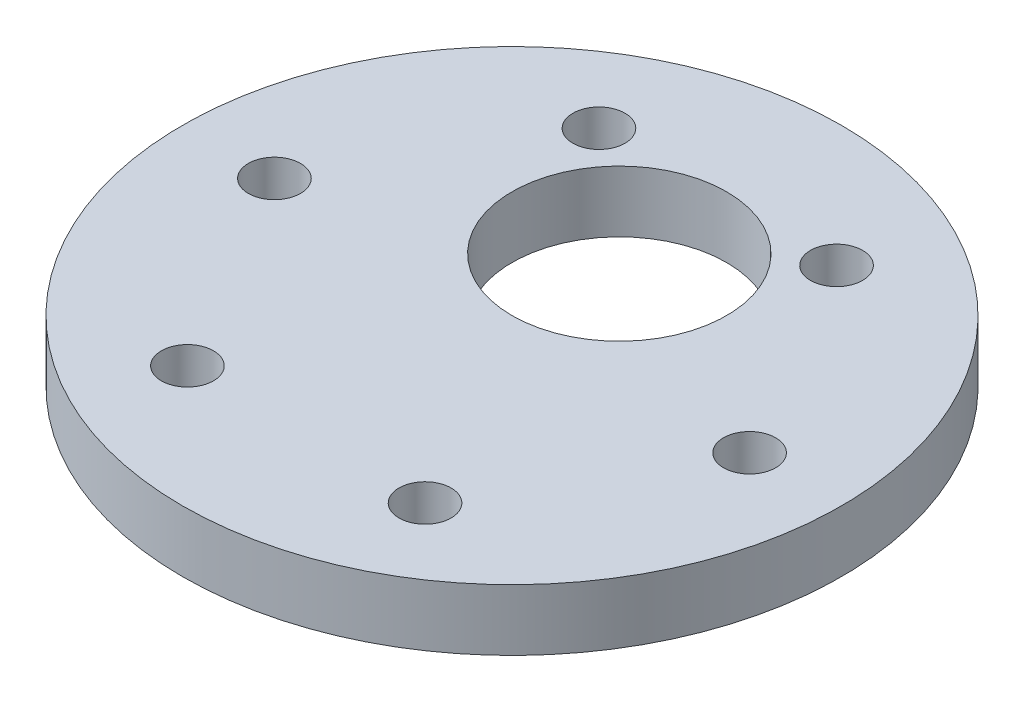
from build123d import *

# Parameters (mm, degrees)
SKETCH3_R           = 21.5
SKETCH3_R_2         = 7
BOSS_EXTRUDE1_DEPTH = 4
SKETCH3_4_R         = 1.7
CUT_EXTRUDE2_DEPTH  = 4
CIRPATTERN1_COUNT   = 6


with BuildPart() as part:
    # Sketch3 → Boss-Extrude1 (new body)
    with BuildSketch(Plane(origin=(0, 0, 0), x_dir=(1, 0, 0), z_dir=(0, 1, 0))):
        Circle(SKETCH3_R)
        with Locations((0, 7)):
            Circle(SKETCH3_R_2, mode=Mode.SUBTRACT)
    extrude(amount=BOSS_EXTRUDE1_DEPTH)

    # Sketch3_4 → Cut-Extrude2 (cut)
    with BuildSketch(Plane(origin=(0, 0, 0), x_dir=(1, 0, 0), z_dir=(0, 1, 0))):
        with Locations((-15.5, 0)):
            Circle(SKETCH3_4_R)
    cut_extrude2 = extrude(amount=CUT_EXTRUDE2_DEPTH, mode=Mode.SUBTRACT)

    # CirPattern1: Cut-Extrude2 ×6 about axis
    cirpattern1_axis = Axis((0, 0, 0), (0, 1, 0))
    for i in range(1, CIRPATTERN1_COUNT):
        add(cut_extrude2.rotate(cirpattern1_axis, i * 360 / CIRPATTERN1_COUNT), mode=Mode.SUBTRACT)


solid = part.part
